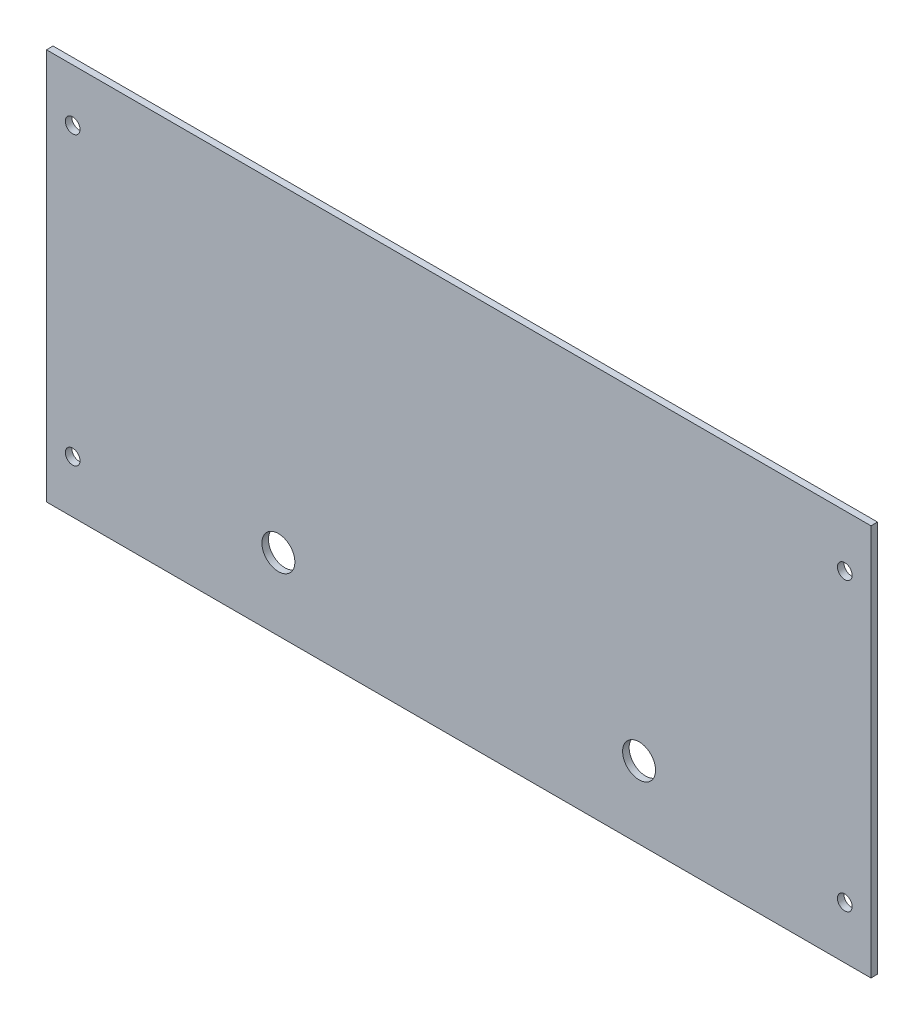
from build123d import *

# Parameters (mm, degrees)
SKETCH1_W           = 400
SKETCH1_H           = 190
SKETCH1_R           = 8
SKETCH1_R_2         = 3.5687
BOSS_EXTRUDE1_DEPTH = 3.175


with BuildPart() as part:
    # Sketch1 → Boss-Extrude1 (new body)
    with BuildSketch(Plane.XY):
        Rectangle(SKETCH1_W, SKETCH1_H)
        with Locations((-87.5, -60)):
            Circle(SKETCH1_R, mode=Mode.SUBTRACT)
        with Locations((87.5, -60)):
            Circle(SKETCH1_R, mode=Mode.SUBTRACT)
        with Locations((-187.3, 69.6)):
            Circle(SKETCH1_R_2, mode=Mode.SUBTRACT)
        with Locations((-187.3, -69.6)):
            Circle(SKETCH1_R_2, mode=Mode.SUBTRACT)
        with Locations((187.3, -69.6)):
            Circle(SKETCH1_R_2, mode=Mode.SUBTRACT)
        with Locations((187.3, 69.6)):
            Circle(SKETCH1_R_2, mode=Mode.SUBTRACT)
    extrude(amount=BOSS_EXTRUDE1_DEPTH)


solid = part.part
